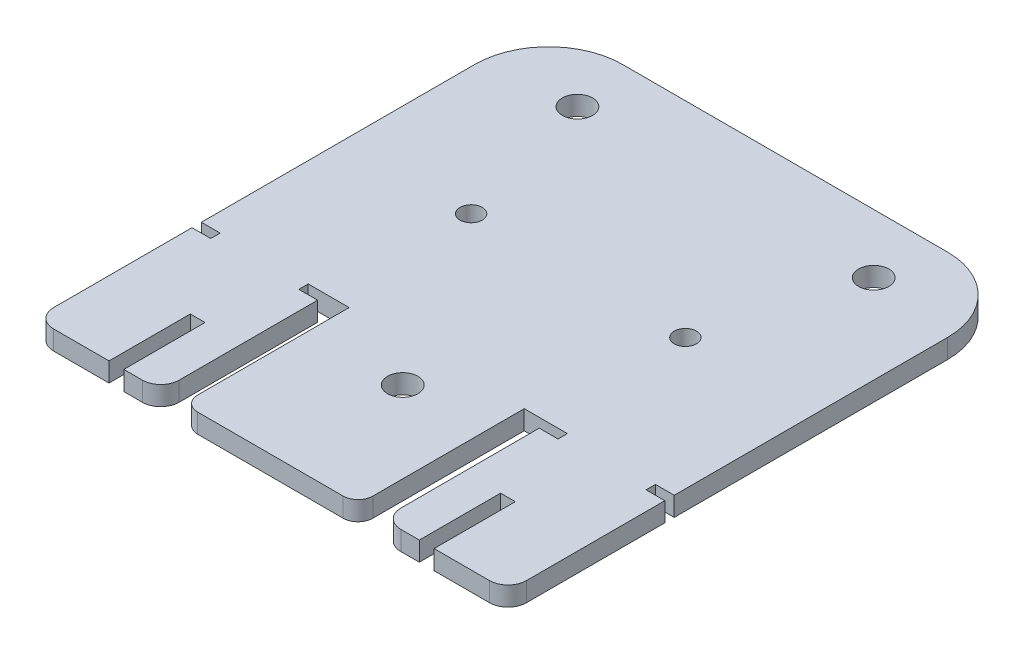
from build123d import *

# Parameters (mm, degrees)
MAIN_BODY_DEPTH          = 2.6
SKETCH2_R                = 2.05
SKETCH2_R_2              = 1.5
SKETCH2_R_3              = 2.0499959
SCREW_HOLES_DEPTH        = 1
SCREW_HOLES_DEPTH_BACK   = 3.6
MAIN_LOWER_BODY_FILLET_R = 2
SKETCH5_W                = 17
SKETCH5_H                = 2.6
BOSS_EXTRUDE1_DEPTH      = 22.5
SKETCH6_W                = 2
SKETCH6_H                = 11
CUT_EXTRUDE1_DEPTH       = 22.5
FILLET2_R                = 2.5
SKETCH7_W                = 2.54
SKETCH7_H                = 1.27
CUT_EXTRUDE2_DEPTH       = 3.6


with BuildPart() as part:
    # Sketch1 → Main Body (new body)
    with BuildSketch(Plane(origin=(0, 0, 0), x_dir=(1, 0, 0), z_dir=(0, 1, 0))):
        with BuildLine():
            Line((11.7, -23.5), (32, -23.5))
            Line((32, -23.5), (32, 13.5))
            ThreePointArc((32, 13.5), (29.071067812, 20.571067812), (22, 23.5))
            Line((22, 23.5), (-22, 23.5))
            ThreePointArc((-22, 23.5), (-29.071067812, 20.571067812), (-32, 13.5))
            Line((-32, 13.5), (-32, -23.5))
            Line((-32, -23.5), (-12, -23.5))
            Line((-12, -23.5), (-12, -46))
            Line((-12, -46), (11.7, -46))
            Line((11.7, -46), (11.7, -23.5))
        make_face()
    extrude(amount=MAIN_BODY_DEPTH)

    # Sketch2 → Screw holes (cut, two sides)
    with BuildSketch(Plane(origin=(0, 2.6, 0), x_dir=(1, 0, 0), z_dir=(0, 1, 0))) as screw_holes_sk:
        with Locations((-20.1, 15.4999906)):
            Circle(SKETCH2_R)
        with Locations((20, 15.5)):
            Circle(SKETCH2_R)
        with Locations((-14.740009048, -4.250005346)):
            Circle(SKETCH2_R_2)
        with Locations((14.259990952, -4.250005346)):
            Circle(SKETCH2_R_2)
        with Locations((0.7, -28.9500094)):
            Circle(SKETCH2_R_3)
    extrude(amount=SCREW_HOLES_DEPTH, mode=Mode.SUBTRACT)
    extrude(screw_holes_sk.sketch, amount=-SCREW_HOLES_DEPTH_BACK, mode=Mode.SUBTRACT)

    # Main lower body Fillet
    main_lower_body_fillet_edges = [part.edges().sort_by_distance(p)[0] for p in [
        (11.7, 1.3, 46),
        (-12, 1.3, 46),
    ]]
    fillet(main_lower_body_fillet_edges, radius=MAIN_LOWER_BODY_FILLET_R)

    # Sketch5 → Boss-Extrude1 (add)
    with BuildSketch(Plane.XY.offset(23.5)):
        with Locations((-23.5, 1.3)):
            Rectangle(SKETCH5_W, SKETCH5_H)
        with Locations((23.5, 1.3)):
            Rectangle(SKETCH5_W, SKETCH5_H)
    extrude(amount=BOSS_EXTRUDE1_DEPTH)

    # Sketch6 → Cut-Extrude1 (cut)
    with BuildSketch(Plane(origin=(0, 2.6, 0), x_dir=(1, 0, 0), z_dir=(0, 1, 0))):
        with Locations((-21, -40.5)):
            Rectangle(SKETCH6_W, SKETCH6_H)
        with Locations((21, -40.5)):
            Rectangle(SKETCH6_W, SKETCH6_H)
    extrude(amount=-CUT_EXTRUDE1_DEPTH, mode=Mode.SUBTRACT)

    # Fillet2
    fillet2_edges = [part.edges().sort_by_distance(p)[0] for p in [
        (-32, 1.3, 46),
        (-15, 1.3, 46),
        (32, 1.3, 46),
        (15, 1.3, 46),
    ]]
    fillet(fillet2_edges, radius=FILLET2_R)

    # Sketch7 → Cut-Extrude2 (cut, through all)
    with BuildSketch(Plane(origin=(0, 2.6, 0), x_dir=(1, 0, 0), z_dir=(0, 1, 0))):
        with Locations((-30.73, -24.135)):
            Rectangle(SKETCH7_W, SKETCH7_H)
        with Locations((30.73, -24.135)):
            Rectangle(SKETCH7_W, SKETCH7_H)
        with Locations((-16.27, -24.135)):
            Rectangle(SKETCH7_W, SKETCH7_H)
        with Locations((16.27, -24.135)):
            Rectangle(SKETCH7_W, SKETCH7_H)
    extrude(amount=-CUT_EXTRUDE2_DEPTH, mode=Mode.SUBTRACT)


solid = part.part
